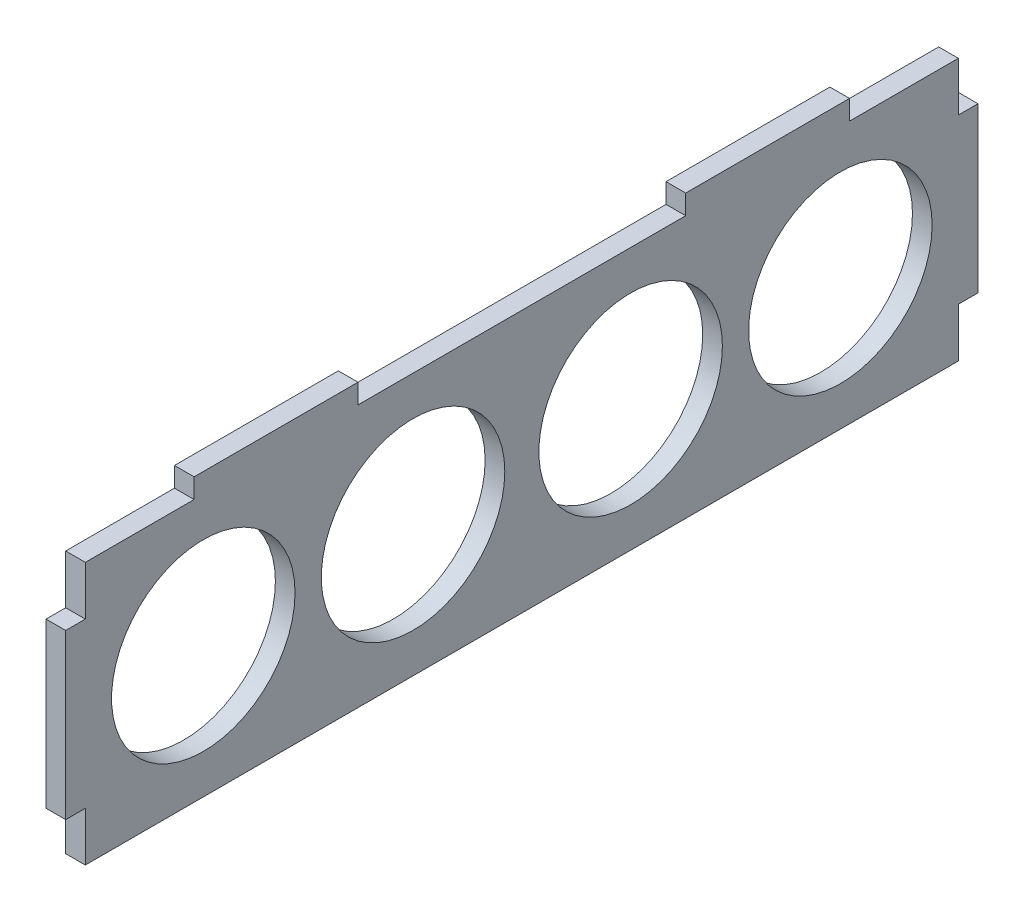
from build123d import *

# Parameters (mm, degrees)
SKETCH1_R           = 14
BOSS_EXTRUDE1_DEPTH = 3


with BuildPart() as part:
    # Sketch1 → Boss-Extrude1 (new body)
    with BuildSketch(Plane(origin=(0, 0, 0), x_dir=(0, 0, -1), z_dir=(1, 0, 0))):
        Polygon((-66.6, -12.5), (-66.6, -20), (66.6, -20), (66.6, -12.5), (69.6, -12.5), (69.6, 12.5), (66.6, 12.5), (66.6, 20), (50, 20), (50, 23), (25, 23), (25, 20), (-25, 20), (-25, 23), (-50, 23), (-50, 20), (-66.6, 20), (-66.6, 12.5), (-69.6, 12.5), (-69.6, -12.5), align=None)
        with Locations((-48.6, 0)):
            Circle(SKETCH1_R, mode=Mode.SUBTRACT)
        with Locations((-16.6, 0)):
            Circle(SKETCH1_R, mode=Mode.SUBTRACT)
        with Locations((16.6, 0)):
            Circle(SKETCH1_R, mode=Mode.SUBTRACT)
        with Locations((48.6, 0)):
            Circle(SKETCH1_R, mode=Mode.SUBTRACT)
    extrude(amount=BOSS_EXTRUDE1_DEPTH)


solid = part.part
